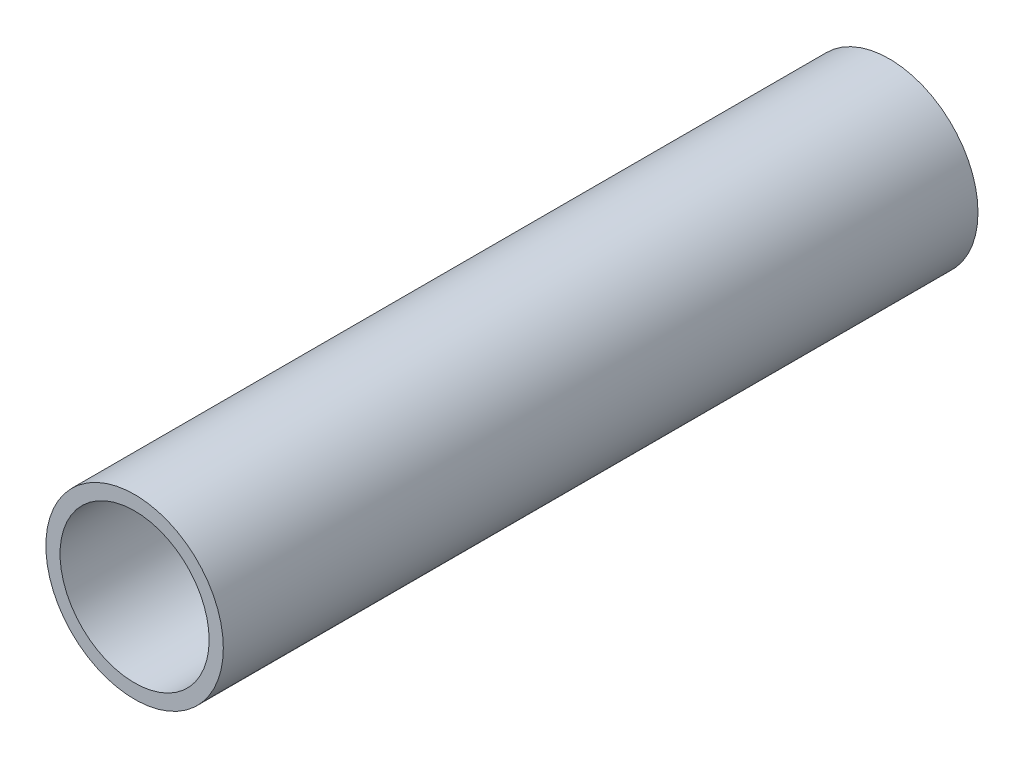
from build123d import *

# Parameters (mm, degrees)
SKETCH2_R           = 6.35
SKETCH2_R_2         = 5.334
BOSS_EXTRUDE1_DEPTH = 54


with BuildPart() as part:
    # Sketch2 → Boss-Extrude1 (new body)
    with BuildSketch(Plane.XY):
        Circle(SKETCH2_R)
        Circle(SKETCH2_R_2, mode=Mode.SUBTRACT)
    extrude(amount=BOSS_EXTRUDE1_DEPTH)


solid = part.part
